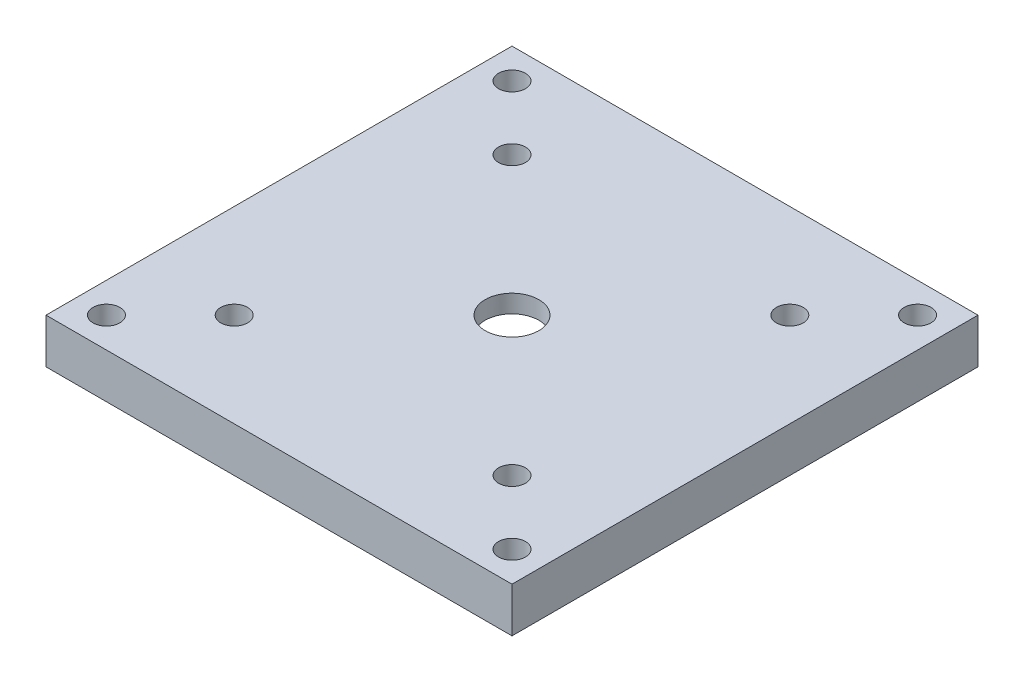
from build123d import *

# Parameters (mm, degrees)
SKETCH1_W           = 52
SKETCH1_H           = 52
BOSS_EXTRUDE1_DEPTH = 5
SKETCH1_5_R         = 1.5
CUT_EXTRUDE2_DEPTH  = 13
SKETCH1_8_R         = 10
CUT_EXTRUDE5_DEPTH  = 3
SKETCH1_9_R         = 3
CUT_EXTRUDE6_DEPTH  = 24
SKETCH1_10_R        = 1.5
CUT_EXTRUDE7_DEPTH  = 24


with BuildPart() as part:
    # Sketch1 → Boss-Extrude1 (new body)
    with BuildSketch(Plane(origin=(0, 0, 0), x_dir=(1, 0, 0), z_dir=(0, 1, 0))):
        Rectangle(SKETCH1_W, SKETCH1_H)
    extrude(amount=BOSS_EXTRUDE1_DEPTH)

    # Sketch1_5 → Cut-Extrude2 (cut)
    with BuildSketch(Plane(origin=(0, 0, 0), x_dir=(1, 0, 0), z_dir=(0, 1, 0))):
        with Locations((22.627416998, 22.627416998)):
            Circle(SKETCH1_5_R)
        with Locations((22.627416998, -22.627416998)):
            Circle(SKETCH1_5_R)
        with Locations((-22.627416998, 22.627416998)):
            Circle(SKETCH1_5_R)
        with Locations((-22.627416998, -22.627416998)):
            Circle(SKETCH1_5_R)
        with Locations((15.5, -15.5)):
            Circle(SKETCH1_5_R)
        with Locations((-15.5, 15.5)):
            Circle(SKETCH1_5_R)
    extrude(amount=CUT_EXTRUDE2_DEPTH, mode=Mode.SUBTRACT)

    # Sketch1_8 → Cut-Extrude5 (cut)
    with BuildSketch(Plane(origin=(0, 0, 0), x_dir=(1, 0, 0), z_dir=(0, 1, 0))):
        Circle(SKETCH1_8_R)
    extrude(amount=CUT_EXTRUDE5_DEPTH, mode=Mode.SUBTRACT)

    # Sketch1_9 → Cut-Extrude6 (cut)
    with BuildSketch(Plane(origin=(0, 0, 0), x_dir=(1, 0, 0), z_dir=(0, 1, 0))):
        Circle(SKETCH1_9_R)
    extrude(amount=CUT_EXTRUDE6_DEPTH, mode=Mode.SUBTRACT)

    # Sketch1_10 → Cut-Extrude7 (cut)
    with BuildSketch(Plane(origin=(0, 0, 0), x_dir=(1, 0, 0), z_dir=(0, 1, 0))):
        with Locations((15.5, 15.5)):
            Circle(SKETCH1_10_R)
        with Locations((-15.5, -15.5)):
            Circle(SKETCH1_10_R)
    extrude(amount=CUT_EXTRUDE7_DEPTH, mode=Mode.SUBTRACT)


solid = part.part
